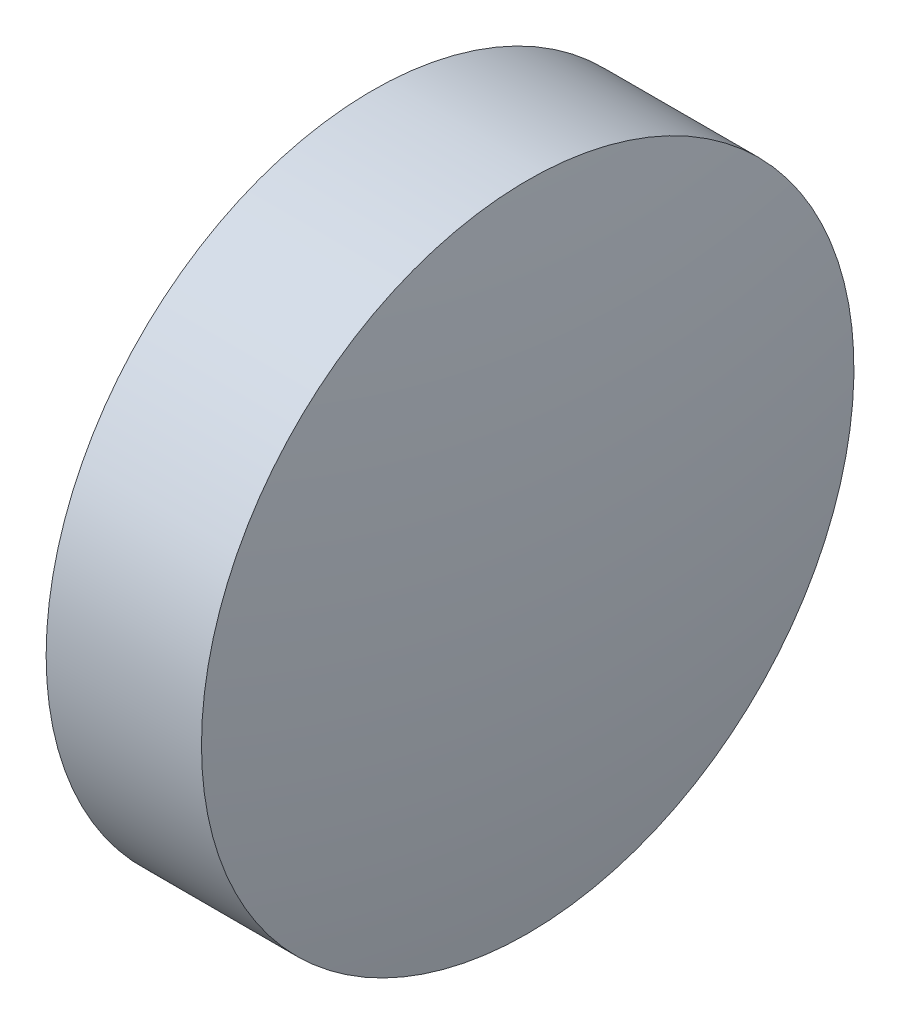
from build123d import *


with BuildPart() as part:
    # 草图2 → 旋转2 (revolve)
    with BuildSketch(Plane.XY, mode=Mode.PRIVATE) as revolve_2_sk:
        with BuildLine():
            Line((444.284406446, 32.74152775), (444.284406446, 35.89152775))
            Line((444.284406446, 35.89152775), (445.784406446, 35.89152775))
            ThreePointArc((445.784406446, 35.89152775), (445.986782919, 34.322302876), (446.054406446, 32.74152775))
            Line((446.054406446, 32.74152775), (444.284406446, 32.74152775))
        make_face()
    revolve(revolve_2_sk.sketch.rotate(Axis((443.423768357, 32.74152775, 0), (1, 0, 0)), 180), axis=Axis((443.423768357, 32.74152775, 0), (1, 0, 0)))  # turned: the seam where the file's is


solid = part.part
